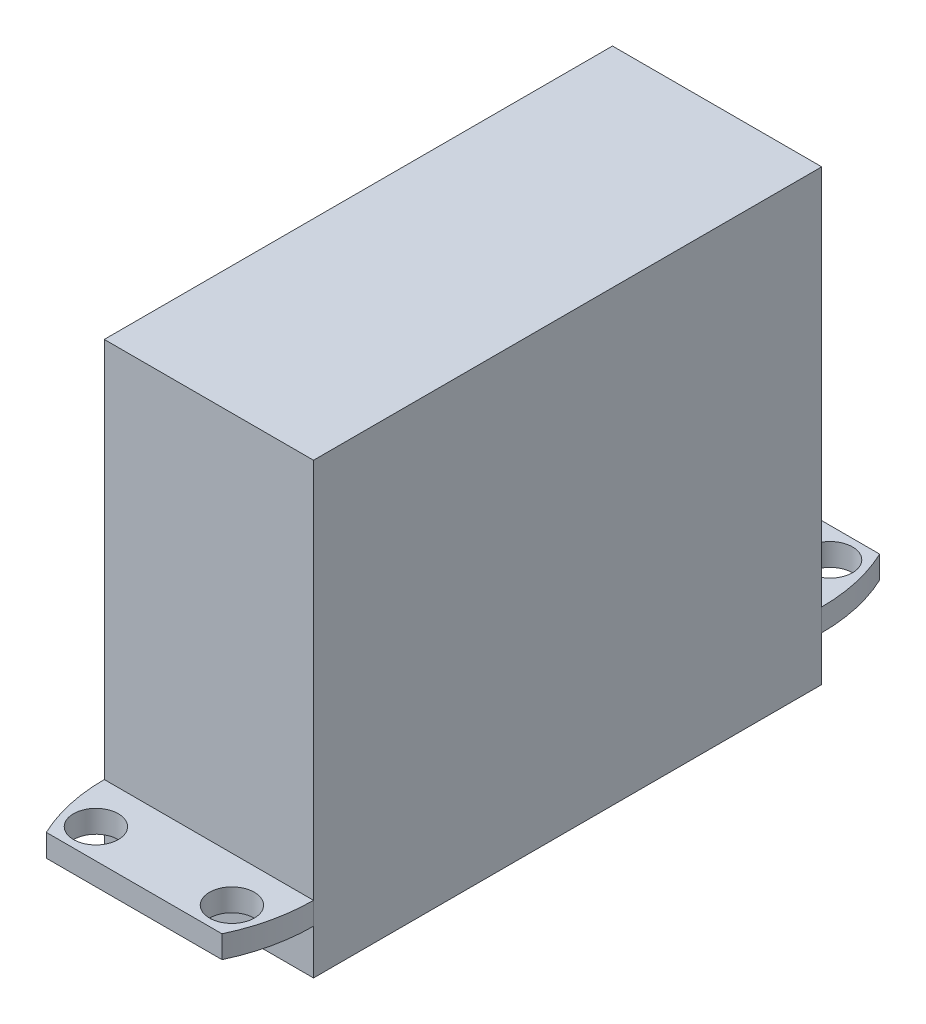
from build123d import *

# Parameters (mm, degrees)
SKETCH1_W           = 14
SKETCH1_H           = 34
BOSS_EXTRUDE1_DEPTH = 30
SKETCH1_3_R         = 2.5
CUT_EXTRUDE1_DEPTH  = 12
BOSS_EXTRUDE2_START = -3
SKETCH4_R           = 1.5
BOSS_EXTRUDE2_DEPTH = 1.5


with BuildPart() as part:
    # Sketch1 → Boss-Extrude1 (new body)
    with BuildSketch(Plane(origin=(0, 0, 0), x_dir=(1, 0, 0), z_dir=(0, 1, 0))):
        Rectangle(SKETCH1_W, SKETCH1_H)
    extrude(amount=BOSS_EXTRUDE1_DEPTH)

    # Sketch1_3 → Cut-Extrude1 (cut)
    with BuildSketch(Plane(origin=(0, 0, 0), x_dir=(1, 0, 0), z_dir=(0, 1, 0))):
        with Locations((0, -10)):
            Circle(SKETCH1_3_R)
    extrude(amount=CUT_EXTRUDE1_DEPTH, mode=Mode.SUBTRACT)

    # Sketch4 → Boss-Extrude2 (add)
    with BuildSketch(Plane.XZ.offset(BOSS_EXTRUDE2_START)):
        with BuildLine():
            ThreePointArc((-5.877806956, 22), (-6.716005023, 19.562192285), (-7, 17))
            Line((-7, 17), (7, 17))
            ThreePointArc((7, 17), (6.716005023, 19.562192285), (5.877806956, 22))
            Line((5.877806956, 22), (-5.877806956, 22))
        make_face()
        with Locations((-4.55, 20.01)):
            Circle(SKETCH4_R, mode=Mode.SUBTRACT)
        with Locations((4.55, 20.01)):
            Circle(SKETCH4_R, mode=Mode.SUBTRACT)
    boss_extrude2 = extrude(amount=-BOSS_EXTRUDE2_DEPTH)

    # Mirror1: Boss-Extrude2 across plane
    add(boss_extrude2.mirror(Plane.XY))


solid = part.part
